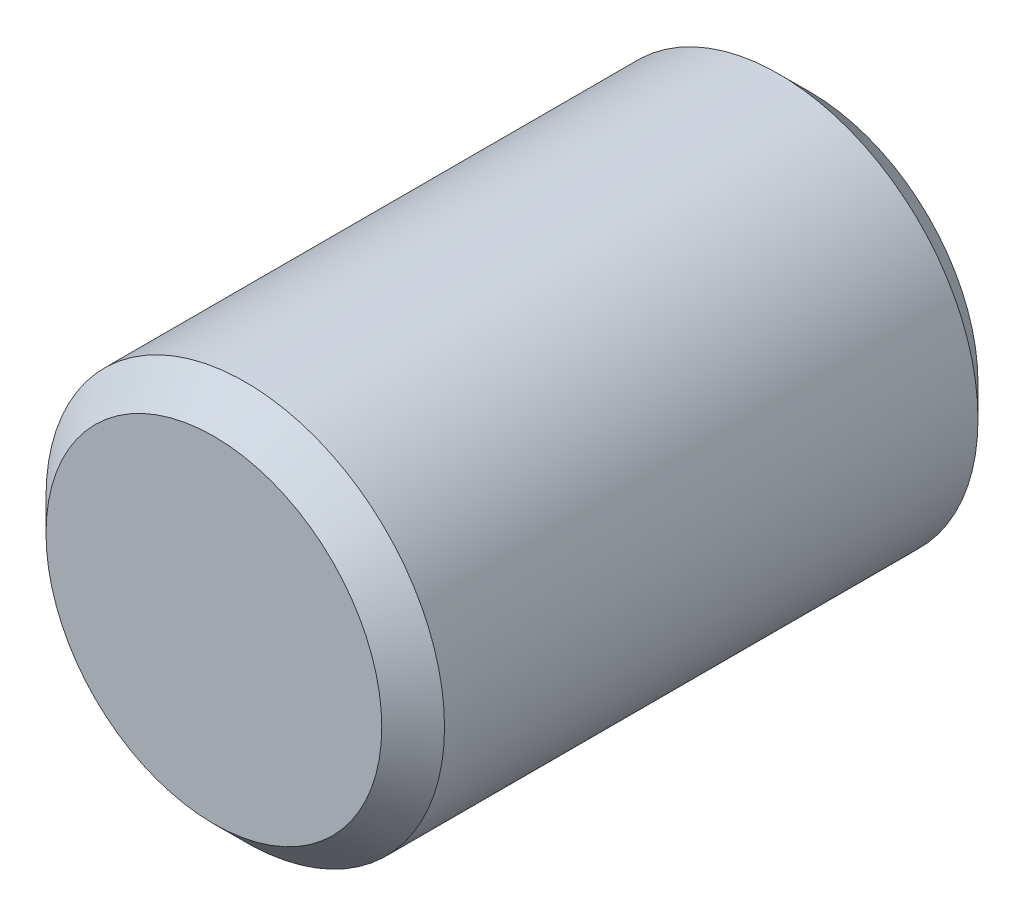
from build123d import *

# Parameters (mm, degrees)
BOSS_EXTRUDE1_DEPTH      = 4.75
BOSS_EXTRUDE1_DEPTH_BACK = 4.75
SKETCH1_R                = 3.175
CHAMFER1_SIZE            = 0.5


with BuildPart() as part:
    # Sketch1 → Boss-Extrude1 (new, two sides: drawn at the far end of the back side and taken through both)
    with BuildSketch(Plane.XY.offset(-BOSS_EXTRUDE1_DEPTH_BACK)):
        Circle(SKETCH1_R)
    extrude(amount=BOSS_EXTRUDE1_DEPTH + BOSS_EXTRUDE1_DEPTH_BACK)

    # Chamfer1
    chamfer1_edges = [part.edges().sort_by_distance(p)[0] for p in [
        (-3.175, 0, -4.75),
        (-3.175, 0, 4.75),
    ]]
    chamfer(chamfer1_edges, length=CHAMFER1_SIZE)


solid = part.part
